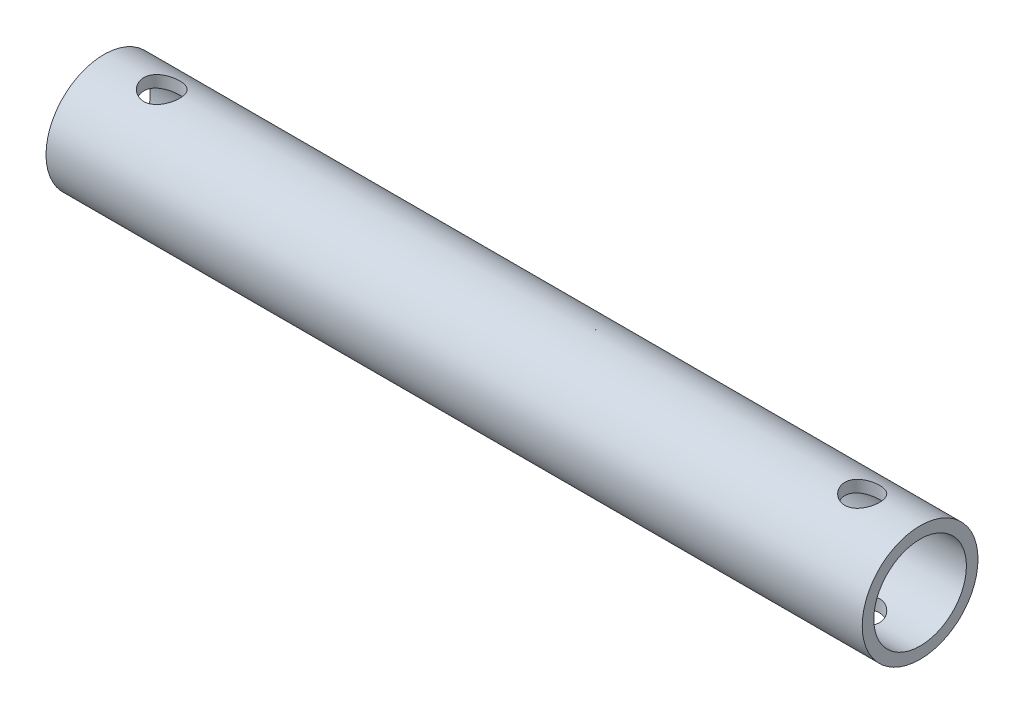
from build123d import *

# Parameters (mm, degrees)
SKETCH_1_R          = 10
SKETCH_1_R_2        = 8
EXTRUDE_1_DEPTH     = 107
SKETCH_2_R          = 10
SKETCH_2_R_2        = 8
EXTRUDE_2_DEPTH     = 34
SKETCH_3_R          = 3
CUT_EXTRUDE_1_DEPTH = 15
SKETCH_4_R          = 3.1
CUT_EXTRUDE_2_DEPTH = 10


with BuildPart() as part:
    # 草图1 → 凸台-拉伸1 (new body)
    with BuildSketch(Plane(origin=(0, 0, 0), x_dir=(0, 0, -1), z_dir=(1, 0, 0))):
        Circle(SKETCH_1_R)
        Circle(SKETCH_1_R_2, mode=Mode.SUBTRACT)
    extrude(amount=EXTRUDE_1_DEPTH)

    # 草图2 → 凸台-拉伸2 (add)
    with BuildSketch(Plane.ZY):
        Circle(SKETCH_2_R)
        Circle(SKETCH_2_R_2, mode=Mode.SUBTRACT)
    extrude(amount=EXTRUDE_2_DEPTH)

    # 草图3 → 切除-拉伸1 (cut, symmetric)
    with BuildSketch(Plane(origin=(0, 0, 0), x_dir=(1, 0, 0), z_dir=(0, 1, 0))):
        with Locations((97, 0)):
            Circle(SKETCH_3_R)
    extrude(amount=CUT_EXTRUDE_1_DEPTH, both=True, mode=Mode.SUBTRACT)

    # 草图4 → 切除-拉伸2 (cut, symmetric)
    with BuildSketch(Plane(origin=(0, 0, 0), x_dir=(1, 0, 0), z_dir=(0, 1, 0))):
        with Locations((-24, 0)):
            Circle(SKETCH_4_R)
    extrude(amount=CUT_EXTRUDE_2_DEPTH, both=True, mode=Mode.SUBTRACT)


solid = part.part
